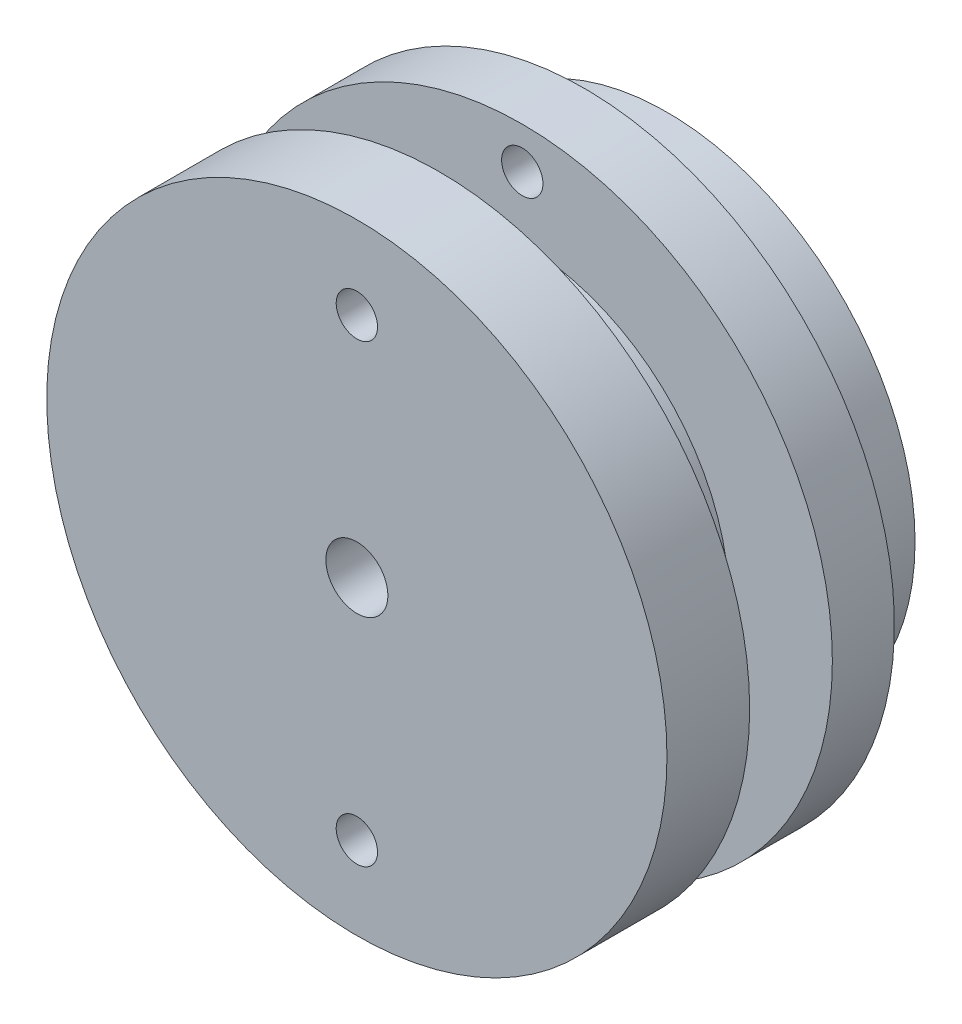
from build123d import *

# Parameters (mm, degrees)
SKETCH1_R           = 15
SKETCH1_R_2         = 1.2
SKETCH1_W           = 9.3
SKETCH1_H           = 9.3
BOSS_EXTRUDE1_DEPTH = 7
SKETCH2_R           = 10
SKETCH2_R_2         = 1.5
SKETCH2_W           = 1.35
SKETCH2_H           = 9.3
BOSS_EXTRUDE2_DEPTH = 4
SKETCH3_R           = 15
SKETCH3_R_2         = 1.5
BOSS_EXTRUDE3_DEPTH = 4
SKETCH4_R           = 15
SKETCH4_R_2         = 12
CUT_EXTRUDE1_DEPTH  = 4
SKETCH5_R           = 1
CUT_EXTRUDE2_DEPTH  = 3
SKETCH6_R           = 1
CUT_EXTRUDE5_DEPTH  = 5


with BuildPart() as part:
    # Sketch1 → Boss-Extrude1 (new body)
    with BuildSketch(Plane.XY):
        Circle(SKETCH1_R)
        with Locations((0, 7.75)):
            Circle(SKETCH1_R_2, mode=Mode.SUBTRACT)
        with Locations((7.75, 0)):
            Circle(SKETCH1_R_2, mode=Mode.SUBTRACT)
        with Locations((0, -7.75)):
            Circle(SKETCH1_R_2, mode=Mode.SUBTRACT)
        with Locations((-7.75, 0)):
            Circle(SKETCH1_R_2, mode=Mode.SUBTRACT)
        Rectangle(SKETCH1_W, SKETCH1_H, mode=Mode.SUBTRACT)
    extrude(amount=BOSS_EXTRUDE1_DEPTH)

    # Sketch2 → Boss-Extrude2 (add)
    with BuildSketch(Plane.XY.offset(7)):
        Circle(SKETCH2_R)
        Circle(SKETCH2_R_2, mode=Mode.SUBTRACT)
        with Locations((-3.975, 0)):
            Rectangle(SKETCH2_W, SKETCH2_H, mode=Mode.SUBTRACT)
        with Locations((3.975, 0)):
            Rectangle(SKETCH2_W, SKETCH2_H, mode=Mode.SUBTRACT)
    extrude(amount=BOSS_EXTRUDE2_DEPTH)

    # Sketch3 → Boss-Extrude3 (add)
    with BuildSketch(Plane.XY.offset(11)):
        Circle(SKETCH3_R)
        Circle(SKETCH3_R_2, mode=Mode.SUBTRACT)
    extrude(amount=BOSS_EXTRUDE3_DEPTH)

    # Sketch4 → Cut-Extrude1 (cut)
    with BuildSketch(Plane(origin=(0, 0, 0), x_dir=(-1, 0, 0), z_dir=(0, 0, -1))):
        Circle(SKETCH4_R)
        Circle(SKETCH4_R_2, mode=Mode.SUBTRACT)
    extrude(amount=-CUT_EXTRUDE1_DEPTH, mode=Mode.SUBTRACT)

    # Sketch5 → Cut-Extrude2 (cut)
    with BuildSketch(Plane(origin=(0, 0, 4), x_dir=(-1, 0, 0), z_dir=(0, 0, -1))):
        with Locations((0, 13)):
            Circle(SKETCH5_R)
        with Locations((0, -13)):
            Circle(SKETCH5_R)
    extrude(amount=-CUT_EXTRUDE2_DEPTH, mode=Mode.SUBTRACT)

    # Sketch6 → Cut-Extrude5 (cut, through all)
    with BuildSketch(Plane(origin=(0, 0, 11), x_dir=(-1, 0, 0), z_dir=(0, 0, -1))):
        with Locations((0, 11)):
            Circle(SKETCH6_R)
        with Locations((0, -11)):
            Circle(SKETCH6_R)
    extrude(amount=-CUT_EXTRUDE5_DEPTH, mode=Mode.SUBTRACT)


solid = part.part
